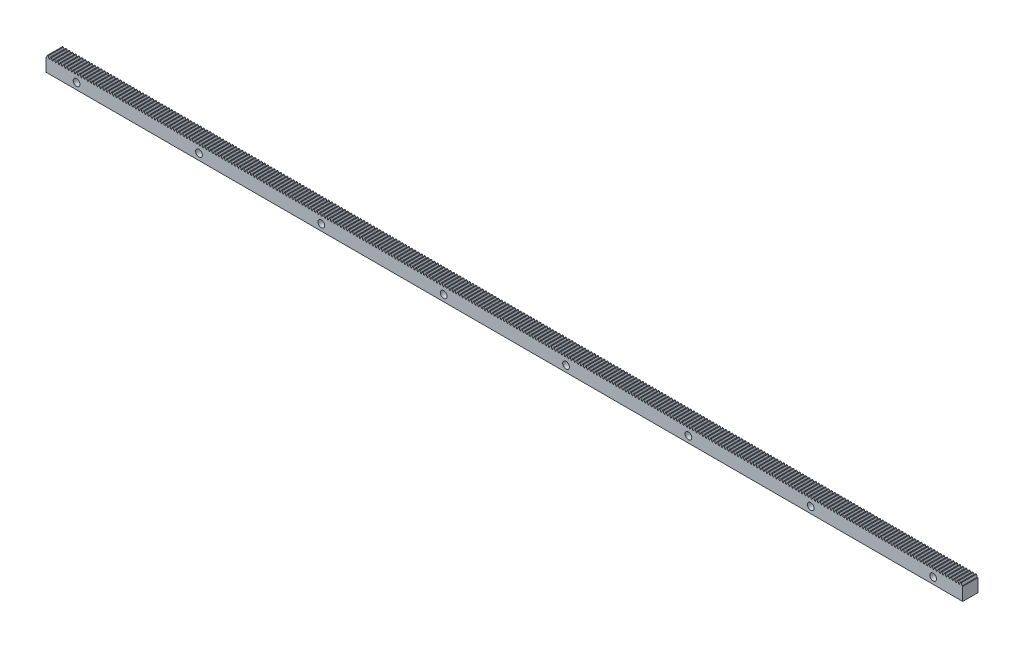
from build123d import *

# Parameters (mm, degrees)
BOSS_EXTRU_1_DEPTH                                  = 15
CBORE_FOR_M6_HEX_SOCKET_HEAD_CAP_SCREW1_D           = 6.6
CBORE_FOR_M6_HEX_SOCKET_HEAD_CAP_SCREW1_DEPTH       = 23
CBORE_FOR_M6_HEX_SOCKET_HEAD_CAP_SCREW1_CBORE_D     = 11
CBORE_FOR_M6_HEX_SOCKET_HEAD_CAP_SCREW1_CBORE_DEPTH = 6.4
CBORE_FOR_M6_HEX_SOCKET_HEAD_CAP_SCREW1_TIP         = 1.982840043


with BuildPart() as part:
    # Esquisse1 → Boss.-Extru.1 (new body)
    with BuildSketch(Plane.XY):
        Polygon((3.135070948, 7.8), (3.135070948, 0), (3.135070948, -5), (-895.88403, -5), (-895.88403, 7.8), (-895.359669052, 7.8), (-894.558930993, 10.000009736), (-893.716076461, 10.000009736), (-892.915315239, 7.8), (-892.218079052, 7.8), (-891.417340993, 10.000009736), (-890.574486461, 10.000009736), (-889.773725239, 7.8), (-889.076489052, 7.8), (-888.275750993, 10.000009736), (-887.432896461, 10.000009736), (-886.632135239, 7.8), (-885.934899052, 7.8), (-885.134160993, 10.000009736), (-884.291306461, 10.000009736), (-883.490545239, 7.8), (-882.793309052, 7.8), (-881.992570993, 10.000009736), (-881.149716461, 10.000009736), (-880.348955239, 7.8), (-879.651719052, 7.8), (-878.850980993, 10.000009736), (-878.008126461, 10.000009736), (-877.207365239, 7.8), (-876.510129052, 7.8), (-875.709390993, 10.000009736), (-874.866536461, 10.000009736), (-874.065775239, 7.8), (-873.368539052, 7.8), (-872.567800993, 10.000009736), (-871.724946461, 10.000009736), (-870.924185239, 7.8), (-870.226949052, 7.8), (-869.426210993, 10.000009736), (-868.583356461, 10.000009736), (-867.782595239, 7.8), (-867.085359052, 7.8), (-866.284620993, 10.000009736), (-865.441766461, 10.000009736), (-864.641005239, 7.8), (-863.943769052, 7.8), (-863.143030993, 10.000009736), (-862.300176461, 10.000009736), (-861.499415239, 7.8), (-860.802179052, 7.8), (-860.001440993, 10.000009736), (-859.158586461, 10.000009736), (-858.357825239, 7.8), (-857.660589052, 7.8), (-856.859850993, 10.000009736), (-856.016996461, 10.000009736), (-855.216235239, 7.8), (-854.518999052, 7.8), (-853.718260993, 10.000009736), (-852.875406461, 10.000009736), (-852.074645239, 7.8), (-851.377409052, 7.8), (-850.576670993, 10.000009736), (-849.733816461, 10.000009736), (-848.933055239, 7.8), (-848.235819052, 7.8), (-847.435080993, 10.000009736), (-846.592226461, 10.000009736), (-845.791465239, 7.8), (-845.094229052, 7.8), (-844.293490993, 10.000009736), (-843.450636461, 10.000009736), (-842.649875239, 7.8), (-841.952639052, 7.8), (-841.151900993, 10.000009736), (-840.309046461, 10.000009736), (-839.508285239, 7.8), (-838.811049052, 7.8), (-838.010310993, 10.000009736), (-837.167456461, 10.000009736), (-836.366695239, 7.8), (-835.669459052, 7.8), (-834.868720993, 10.000009736), (-834.025866461, 10.000009736), (-833.225105239, 7.8), (-832.527869052, 7.8), (-831.727130993, 10.000009736), (-830.884276461, 10.000009736), (-830.083515239, 7.8), (-829.386279052, 7.8), (-828.585540993, 10.000009736), (-827.742686461, 10.000009736), (-826.941925239, 7.8), (-826.244689052, 7.8), (-825.443950993, 10.000009736), (-824.601096461, 10.000009736), (-823.800335239, 7.8), (-823.103099052, 7.8), (-822.302360993, 10.000009736), (-821.459506461, 10.000009736), (-820.658745239, 7.8), (-819.961509052, 7.8), (-819.160770993, 10.000009736), (-818.317916461, 10.000009736), (-817.517155239, 7.8), (-816.819919052, 7.8), (-816.019180993, 10.000009736), (-815.176326461, 10.000009736), (-814.375565239, 7.8), (-813.678329052, 7.8), (-812.877590993, 10.000009736), (-812.034736461, 10.000009736), (-811.233975239, 7.8), (-810.536739052, 7.8), (-809.736000993, 10.000009736), (-808.893146461, 10.000009736), (-808.092385239, 7.8), (-807.395149052, 7.8), (-806.594410993, 10.000009736), (-805.751556461, 10.000009736), (-804.950795239, 7.8), (-804.253559052, 7.8), (-803.452820993, 10.000009736), (-802.609966461, 10.000009736), (-801.809205239, 7.8), (-801.111969052, 7.8), (-800.311230993, 10.000009736), (-799.468376461, 10.000009736), (-798.667615239, 7.8), (-797.970379052, 7.8), (-797.169640993, 10.000009736), (-796.326786461, 10.000009736), (-795.526025239, 7.8), (-794.828789052, 7.8), (-794.028050993, 10.000009736), (-793.185196461, 10.000009736), (-792.384435239, 7.8), (-791.687199052, 7.8), (-790.886460993, 10.000009736), (-790.043606461, 10.000009736), (-789.242845239, 7.8), (-788.545609052, 7.8), (-787.744870993, 10.000009736), (-786.902016461, 10.000009736), (-786.101255239, 7.8), (-785.404019052, 7.8), (-784.603280993, 10.000009736), (-783.760426461, 10.000009736), (-782.959665239, 7.8), (-782.262429052, 7.8), (-781.461690993, 10.000009736), (-780.618836461, 10.000009736), (-779.818075239, 7.8), (-779.120839052, 7.8), (-778.320100993, 10.000009736), (-777.477246461, 10.000009736), (-776.676485239, 7.8), (-775.979249052, 7.8), (-775.178510993, 10.000009736), (-774.335656461, 10.000009736), (-773.534895239, 7.8), (-772.837659052, 7.8), (-772.036920993, 10.000009736), (-771.194066461, 10.000009736), (-770.393305239, 7.8), (-769.696069052, 7.8), (-768.895330993, 10.000009736), (-768.052476461, 10.000009736), (-767.251715239, 7.8), (-766.554479052, 7.8), (-765.753740993, 10.000009736), (-764.910886461, 10.000009736), (-764.110125239, 7.8), (-763.412889052, 7.8), (-762.612150993, 10.000009736), (-761.769296461, 10.000009736), (-760.968535239, 7.8), (-760.271299052, 7.8), (-759.470560993, 10.000009736), (-758.627706461, 10.000009736), (-757.826945239, 7.8), (-757.129709052, 7.8), (-756.328970993, 10.000009736), (-755.486116461, 10.000009736), (-754.685355239, 7.8), (-753.988119052, 7.8), (-753.187380993, 10.000009736), (-752.344526461, 10.000009736), (-751.543765239, 7.8), (-750.846529052, 7.8), (-750.045790993, 10.000009736), (-749.202936461, 10.000009736), (-748.402175239, 7.8), (-747.704939052, 7.8), (-746.904200993, 10.000009736), (-746.061346461, 10.000009736), (-745.260585239, 7.8), (-744.563349052, 7.8), (-743.762610993, 10.000009736), (-742.919756461, 10.000009736), (-742.118995239, 7.8), (-741.421759052, 7.8), (-740.621020993, 10.000009736), (-739.778166461, 10.000009736), (-738.977405239, 7.8), (-738.280169052, 7.8), (-737.479430993, 10.000009736), (-736.636576461, 10.000009736), (-735.835815239, 7.8), (-735.138579052, 7.8), (-734.337840993, 10.000009736), (-733.494986461, 10.000009736), (-732.694225239, 7.8), (-731.996989052, 7.8), (-731.196250993, 10.000009736), (-730.353396461, 10.000009736), (-729.552635239, 7.8), (-728.855399052, 7.8), (-728.054660993, 10.000009736), (-727.211806461, 10.000009736), (-726.411045239, 7.8), (-725.713809052, 7.8), (-724.913070993, 10.000009736), (-724.070216461, 10.000009736), (-723.269455239, 7.8), (-722.572219052, 7.8), (-721.771480993, 10.000009736), (-720.928626461, 10.000009736), (-720.127865239, 7.8), (-719.430629052, 7.8), (-718.629890993, 10.000009736), (-717.787036461, 10.000009736), (-716.986275239, 7.8), (-716.289039052, 7.8), (-715.488300993, 10.000009736), (-714.645446461, 10.000009736), (-713.844685239, 7.8), (-713.147449052, 7.8), (-712.346710993, 10.000009736), (-711.503856461, 10.000009736), (-710.703095239, 7.8), (-710.005859052, 7.8), (-709.205120993, 10.000009736), (-708.362266461, 10.000009736), (-707.561505239, 7.8), (-706.864269052, 7.8), (-706.063530993, 10.000009736), (-705.220676461, 10.000009736), (-704.419915239, 7.8), (-703.722679052, 7.8), (-702.921940993, 10.000009736), (-702.079086461, 10.000009736), (-701.278325239, 7.8), (-700.581089052, 7.8), (-699.780350993, 10.000009736), (-698.937496461, 10.000009736), (-698.136735239, 7.8), (-697.439499052, 7.8), (-696.638760993, 10.000009736), (-695.795906461, 10.000009736), (-694.995145239, 7.8), (-694.297909052, 7.8), (-693.497170993, 10.000009736), (-692.654316461, 10.000009736), (-691.853555239, 7.8), (-691.156319052, 7.8), (-690.355580993, 10.000009736), (-689.512726461, 10.000009736), (-688.711965239, 7.8), (-688.014729052, 7.8), (-687.213990993, 10.000009736), (-686.371136461, 10.000009736), (-685.570375239, 7.8), (-684.873139052, 7.8), (-684.072400993, 10.000009736), (-683.229546461, 10.000009736), (-682.428785239, 7.8), (-681.731549052, 7.8), (-680.930810993, 10.000009736), (-680.087956461, 10.000009736), (-679.287195239, 7.8), (-678.589959052, 7.8), (-677.789220993, 10.000009736), (-676.946366461, 10.000009736), (-676.145605239, 7.8), (-675.448369052, 7.8), (-674.647630993, 10.000009736), (-673.804776462, 10.000009736), (-673.004015239, 7.8), (-672.306779052, 7.8), (-671.506040993, 10.000009736), (-670.663186462, 10.000009736), (-669.862425239, 7.8), (-669.165189052, 7.8), (-668.364450993, 10.000009736), (-667.521596462, 10.000009736), (-666.720835239, 7.8), (-666.023599052, 7.8), (-665.222860993, 10.000009736), (-664.380006462, 10.000009736), (-663.579245239, 7.8), (-662.882009052, 7.8), (-662.081270993, 10.000009736), (-661.238416462, 10.000009736), (-660.437655239, 7.8), (-659.740419052, 7.8), (-658.939680993, 10.000009736), (-658.096826462, 10.000009736), (-657.296065239, 7.8), (-656.598829052, 7.8), (-655.798090993, 10.000009736), (-654.955236462, 10.000009736), (-654.154475239, 7.8), (-653.457239052, 7.8), (-652.656500993, 10.000009736), (-651.813646462, 10.000009736), (-651.012885239, 7.8), (-650.315649052, 7.8), (-649.514910993, 10.000009736), (-648.672056462, 10.000009736), (-647.871295239, 7.8), (-647.174059052, 7.8), (-646.373320993, 10.000009736), (-645.530466462, 10.000009736), (-644.729705239, 7.8), (-644.032469052, 7.8), (-643.231730993, 10.000009736), (-642.388876462, 10.000009736), (-641.588115239, 7.8), (-640.890879052, 7.8), (-640.090140993, 10.000009736), (-639.247286462, 10.000009736), (-638.446525239, 7.8), (-637.749289052, 7.8), (-636.948550993, 10.000009736), (-636.105696462, 10.000009736), (-635.304935239, 7.8), (-634.607699052, 7.8), (-633.806960993, 10.000009736), (-632.964106462, 10.000009736), (-632.163345239, 7.8), (-631.466109052, 7.8), (-630.665370993, 10.000009736), (-629.822516462, 10.000009736), (-629.021755239, 7.8), (-628.324519052, 7.8), (-627.523780993, 10.000009736), (-626.680926462, 10.000009736), (-625.880165239, 7.8), (-625.182929052, 7.8), (-624.382190993, 10.000009736), (-623.539336462, 10.000009736), (-622.738575239, 7.8), (-622.041339052, 7.8), (-621.240600993, 10.000009736), (-620.397746462, 10.000009736), (-619.596985239, 7.8), (-618.899749052, 7.8), (-618.099010993, 10.000009736), (-617.256156462, 10.000009736), (-616.455395239, 7.8), (-615.758159052, 7.8), (-614.957420993, 10.000009736), (-614.114566462, 10.000009736), (-613.313805239, 7.8), (-612.616569052, 7.8), (-611.815830993, 10.000009736), (-610.972976462, 10.000009736), (-610.172215239, 7.8), (-609.474979052, 7.8), (-608.674240993, 10.000009736), (-607.831386462, 10.000009736), (-607.030625239, 7.8), (-606.333389052, 7.8), (-605.532650993, 10.000009736), (-604.689796462, 10.000009736), (-603.889035239, 7.8), (-603.191799052, 7.8), (-602.391060993, 10.000009736), (-601.548206462, 10.000009736), (-600.747445239, 7.8), (-600.050209052, 7.8), (-599.249470993, 10.000009736), (-598.406616462, 10.000009736), (-597.605855239, 7.8), (-596.908619052, 7.8), (-596.107880993, 10.000009736), (-595.265026462, 10.000009736), (-594.464265239, 7.8), (-593.767029052, 7.8), (-592.966290993, 10.000009736), (-592.123436462, 10.000009736), (-591.322675239, 7.8), (-590.625439052, 7.8), (-589.824700993, 10.000009736), (-588.981846462, 10.000009736), (-588.181085239, 7.8), (-587.483849052, 7.8), (-586.683110993, 10.000009736), (-585.840256462, 10.000009736), (-585.039495239, 7.8), (-584.342259052, 7.8), (-583.541520993, 10.000009736), (-582.698666462, 10.000009736), (-581.897905239, 7.8), (-581.200669052, 7.8), (-580.399930993, 10.000009736), (-579.557076462, 10.000009736), (-578.756315239, 7.8), (-578.059079052, 7.8), (-577.258340993, 10.000009736), (-576.415486462, 10.000009736), (-575.614725239, 7.8), (-574.917489052, 7.8), (-574.116750993, 10.000009736), (-573.273896462, 10.000009736), (-572.473135239, 7.8), (-571.775899052, 7.8), (-570.975160993, 10.000009736), (-570.132306462, 10.000009736), (-569.331545239, 7.8), (-568.634309052, 7.8), (-567.833570993, 10.000009736), (-566.990716462, 10.000009736), (-566.189955239, 7.8), (-565.492719052, 7.8), (-564.691980993, 10.000009736), (-563.849126462, 10.000009736), (-563.048365239, 7.8), (-562.351129052, 7.8), (-561.550390993, 10.000009736), (-560.707536462, 10.000009736), (-559.906775239, 7.8), (-559.209539052, 7.8), (-558.408800993, 10.000009736), (-557.565946462, 10.000009736), (-556.765185239, 7.8), (-556.067949052, 7.8), (-555.267210993, 10.000009736), (-554.424356462, 10.000009736), (-553.623595239, 7.8), (-552.926359052, 7.8), (-552.125620993, 10.000009736), (-551.282766462, 10.000009736), (-550.482005239, 7.8), (-549.784769052, 7.8), (-548.984030993, 10.000009736), (-548.141176462, 10.000009736), (-547.340415239, 7.8), (-546.643179052, 7.8), (-545.842440993, 10.000009736), (-544.999586462, 10.000009736), (-544.198825239, 7.8), (-543.501589052, 7.8), (-542.700850993, 10.000009736), (-541.857996462, 10.000009736), (-541.057235239, 7.8), (-540.359999052, 7.8), (-539.559260993, 10.000009736), (-538.716406462, 10.000009736), (-537.915645239, 7.8), (-537.218409052, 7.8), (-536.417670993, 10.000009736), (-535.574816462, 10.000009736), (-534.774055239, 7.8), (-534.076819052, 7.8), (-533.276080993, 10.000009736), (-532.433226462, 10.000009736), (-531.632465239, 7.8), (-530.935229052, 7.8), (-530.134490993, 10.000009736), (-529.291636462, 10.000009736), (-528.490875239, 7.8), (-527.793639052, 7.8), (-526.992900993, 10.000009736), (-526.150046462, 10.000009736), (-525.349285239, 7.8), (-524.652049052, 7.8), (-523.851310993, 10.000009736), (-523.008456462, 10.000009736), (-522.207695239, 7.8), (-521.510459052, 7.8), (-520.709720993, 10.000009736), (-519.866866462, 10.000009736), (-519.066105239, 7.8), (-518.368869052, 7.8), (-517.568130993, 10.000009736), (-516.725276462, 10.000009736), (-515.924515239, 7.8), (-515.227279052, 7.8), (-514.426540993, 10.000009736), (-513.583686462, 10.000009736), (-512.782925239, 7.8), (-512.085689052, 7.8), (-511.284950993, 10.000009736), (-510.442096462, 10.000009736), (-509.641335239, 7.8), (-508.944099052, 7.8), (-508.143360993, 10.000009736), (-507.300506462, 10.000009736), (-506.499745239, 7.8), (-505.802509052, 7.8), (-505.001770993, 10.000009736), (-504.158916462, 10.000009736), (-503.358155239, 7.8), (-502.660919052, 7.8), (-501.860180993, 10.000009736), (-501.017326462, 10.000009736), (-500.216565239, 7.8), (-499.519329052, 7.8), (-498.718590993, 10.000009736), (-497.875736462, 10.000009736), (-497.074975239, 7.8), (-496.377739052, 7.8), (-495.577000993, 10.000009736), (-494.734146462, 10.000009736), (-493.933385239, 7.8), (-493.236149052, 7.8), (-492.435410993, 10.000009736), (-491.592556462, 10.000009736), (-490.791795239, 7.8), (-490.094559052, 7.8), (-489.293820993, 10.000009736), (-488.450966462, 10.000009736), (-487.650205239, 7.8), (-486.952969052, 7.8), (-486.152230993, 10.000009736), (-485.309376462, 10.000009736), (-484.508615239, 7.8), (-483.811379052, 7.8), (-483.010640993, 10.000009736), (-482.167786462, 10.000009736), (-481.367025239, 7.8), (-480.669789052, 7.8), (-479.869050993, 10.000009736), (-479.026196462, 10.000009736), (-478.225435239, 7.8), (-477.528199052, 7.8), (-476.727460993, 10.000009736), (-475.884606462, 10.000009736), (-475.083845239, 7.8), (-474.386609052, 7.8), (-473.585870993, 10.000009736), (-472.743016462, 10.000009736), (-471.942255239, 7.8), (-471.245019052, 7.8), (-470.444280993, 10.000009736), (-469.601426462, 10.000009736), (-468.800665239, 7.8), (-468.103429052, 7.8), (-467.302690993, 10.000009736), (-466.459836462, 10.000009736), (-465.659075239, 7.8), (-464.961839052, 7.8), (-464.161100993, 10.000009736), (-463.318246462, 10.000009736), (-462.517485239, 7.8), (-461.820249052, 7.8), (-461.019510993, 10.000009736), (-460.176656462, 10.000009736), (-459.375895239, 7.8), (-458.678659052, 7.8), (-457.877920993, 10.000009736), (-457.035066462, 10.000009736), (-456.234305239, 7.8), (-455.537069052, 7.8), (-454.736330993, 10.000009736), (-453.893476462, 10.000009736), (-453.092715239, 7.8), (-452.395479052, 7.8), (-451.594740993, 10.000009736), (-450.751886462, 10.000009736), (-449.951125239, 7.8), (-449.253889052, 7.8), (-448.453150993, 10.000009736), (-447.610296462, 10.000009736), (-446.809535239, 7.8), (-446.112299052, 7.8), (-445.311560993, 10.000009736), (-444.468706462, 10.000009736), (-443.667945239, 7.8), (-442.970709052, 7.8), (-442.169970993, 10.000009736), (-441.327116462, 10.000009736), (-440.526355239, 7.8), (-439.829119052, 7.8), (-439.028380993, 10.000009736), (-438.185526462, 10.000009736), (-437.384765239, 7.8), (-436.687529052, 7.8), (-435.886790993, 10.000009736), (-435.043936462, 10.000009736), (-434.243175239, 7.8), (-433.545939052, 7.8), (-432.745200993, 10.000009736), (-431.902346462, 10.000009736), (-431.101585239, 7.8), (-430.404349052, 7.8), (-429.603610993, 10.000009736), (-428.760756462, 10.000009736), (-427.959995239, 7.8), (-427.262759052, 7.8), (-426.462020993, 10.000009736), (-425.619166462, 10.000009736), (-424.818405239, 7.8), (-424.121169052, 7.8), (-423.320430993, 10.000009736), (-422.477576462, 10.000009736), (-421.676815239, 7.8), (-420.979579052, 7.8), (-420.178840993, 10.000009736), (-419.335986462, 10.000009736), (-418.535225239, 7.8), (-417.837989052, 7.8), (-417.037250993, 10.000009736), (-416.194396462, 10.000009736), (-415.393635239, 7.8), (-414.696399052, 7.8), (-413.895660993, 10.000009736), (-413.052806462, 10.000009736), (-412.252045239, 7.8), (-411.554809052, 7.8), (-410.754070993, 10.000009736), (-409.911216462, 10.000009736), (-409.110455239, 7.8), (-408.413219052, 7.8), (-407.612480993, 10.000009736), (-406.769626462, 10.000009736), (-405.968865239, 7.8), (-405.271629052, 7.8), (-404.470890993, 10.000009736), (-403.628036462, 10.000009736), (-402.827275239, 7.8), (-402.130039052, 7.8), (-401.329300993, 10.000009736), (-400.486446462, 10.000009736), (-399.685685239, 7.8), (-398.988449052, 7.8), (-398.187710993, 10.000009736), (-397.344856462, 10.000009736), (-396.544095239, 7.8), (-395.846859052, 7.8), (-395.046120993, 10.000009736), (-394.203266462, 10.000009736), (-393.402505239, 7.8), (-392.705269052, 7.8), (-391.904530993, 10.000009736), (-391.061676462, 10.000009736), (-390.260915239, 7.8), (-389.563679052, 7.8), (-388.762940993, 10.000009736), (-387.920086462, 10.000009736), (-387.119325239, 7.8), (-386.422089052, 7.8), (-385.621350993, 10.000009736), (-384.778496462, 10.000009736), (-383.977735239, 7.8), (-383.280499052, 7.8), (-382.479760993, 10.000009736), (-381.636906462, 10.000009736), (-380.836145239, 7.8), (-380.138909052, 7.8), (-379.338170993, 10.000009736), (-378.495316462, 10.000009736), (-377.694555239, 7.8), (-376.997319052, 7.8), (-376.196580993, 10.000009736), (-375.353726462, 10.000009736), (-374.552965239, 7.8), (-373.855729052, 7.8), (-373.054990993, 10.000009736), (-372.212136462, 10.000009736), (-371.411375239, 7.8), (-370.714139052, 7.8), (-369.913400993, 10.000009736), (-369.070546462, 10.000009736), (-368.269785239, 7.8), (-367.572549052, 7.8), (-366.771810993, 10.000009736), (-365.928956462, 10.000009736), (-365.128195239, 7.8), (-364.430959052, 7.8), (-363.630220993, 10.000009736), (-362.787366462, 10.000009736), (-361.986605239, 7.8), (-361.289369052, 7.8), (-360.488630993, 10.000009736), (-359.645776462, 10.000009736), (-358.845015239, 7.8), (-358.147779052, 7.8), (-357.347040993, 10.000009736), (-356.504186462, 10.000009736), (-355.703425239, 7.8), (-355.006189052, 7.8), (-354.205450993, 10.000009736), (-353.362596462, 10.000009736), (-352.561835239, 7.8), (-351.864599052, 7.8), (-351.063860993, 10.000009736), (-350.221006462, 10.000009736), (-349.420245239, 7.8), (-348.723009052, 7.8), (-347.922270993, 10.000009736), (-347.079416462, 10.000009736), (-346.278655239, 7.8), (-345.581419052, 7.8), (-344.780680993, 10.000009736), (-343.937826462, 10.000009736), (-343.137065239, 7.8), (-342.439829052, 7.8), (-341.639090993, 10.000009736), (-340.796236462, 10.000009736), (-339.995475239, 7.8), (-339.298239052, 7.8), (-338.497500993, 10.000009736), (-337.654646462, 10.000009736), (-336.853885239, 7.8), (-336.156649052, 7.8), (-335.355910993, 10.000009736), (-334.513056462, 10.000009736), (-333.712295239, 7.8), (-333.015059052, 7.8), (-332.214320993, 10.000009736), (-331.371466462, 10.000009736), (-330.570705239, 7.8), (-329.873469052, 7.8), (-329.072730993, 10.000009736), (-328.229876462, 10.000009736), (-327.429115239, 7.8), (-326.731879052, 7.8), (-325.931140993, 10.000009736), (-325.088286462, 10.000009736), (-324.287525239, 7.8), (-323.590289052, 7.8), (-322.789550993, 10.000009736), (-321.946696462, 10.000009736), (-321.145935239, 7.8), (-320.448699052, 7.8), (-319.647960993, 10.000009736), (-318.805106462, 10.000009736), (-318.004345239, 7.8), (-317.307109052, 7.8), (-316.506370993, 10.000009736), (-315.663516462, 10.000009736), (-314.862755239, 7.8), (-314.165519052, 7.8), (-313.364780993, 10.000009736), (-312.521926462, 10.000009736), (-311.721165239, 7.8), (-311.023929052, 7.8), (-310.223190993, 10.000009736), (-309.380336462, 10.000009736), (-308.579575239, 7.8), (-307.882339052, 7.8), (-307.081600993, 10.000009736), (-306.238746462, 10.000009736), (-305.437985239, 7.8), (-304.740749052, 7.8), (-303.940010993, 10.000009736), (-303.097156462, 10.000009736), (-302.296395239, 7.8), (-301.599159052, 7.8), (-300.798420993, 10.000009736), (-299.955566462, 10.000009736), (-299.154805239, 7.8), (-298.457569052, 7.8), (-297.656830993, 10.000009736), (-296.813976462, 10.000009736), (-296.013215239, 7.8), (-295.315979052, 7.8), (-294.515240993, 10.000009736), (-293.672386462, 10.000009736), (-292.871625239, 7.8), (-292.174389052, 7.8), (-291.373650993, 10.000009736), (-290.530796462, 10.000009736), (-289.730035239, 7.8), (-289.032799052, 7.8), (-288.232060993, 10.000009736), (-287.389206462, 10.000009736), (-286.588445239, 7.8), (-285.891209052, 7.8), (-285.090470993, 10.000009736), (-284.247616462, 10.000009736), (-283.446855239, 7.8), (-282.749619052, 7.8), (-281.948880993, 10.000009736), (-281.106026462, 10.000009736), (-280.305265239, 7.8), (-279.608029052, 7.8), (-278.807290993, 10.000009736), (-277.964436462, 10.000009736), (-277.163675239, 7.8), (-276.466439052, 7.8), (-275.665700993, 10.000009736), (-274.822846462, 10.000009736), (-274.022085239, 7.8), (-273.324849052, 7.8), (-272.524110993, 10.000009736), (-271.681256462, 10.000009736), (-270.880495239, 7.8), (-270.183259052, 7.8), (-269.382520993, 10.000009736), (-268.539666462, 10.000009736), (-267.738905239, 7.8), (-267.041669052, 7.8), (-266.240930993, 10.000009736), (-265.398076462, 10.000009736), (-264.597315239, 7.8), (-263.900079052, 7.8), (-263.099340993, 10.000009736), (-262.256486462, 10.000009736), (-261.455725239, 7.8), (-260.758489052, 7.8), (-259.957750993, 10.000009736), (-259.114896462, 10.000009736), (-258.314135239, 7.8), (-257.616899052, 7.8), (-256.816160993, 10.000009736), (-255.973306462, 10.000009736), (-255.172545239, 7.8), (-254.475309052, 7.8), (-253.674570993, 10.000009736), (-252.831716462, 10.000009736), (-252.030955239, 7.8), (-251.333719052, 7.8), (-250.532980993, 10.000009736), (-249.690126462, 10.000009736), (-248.889365239, 7.8), (-248.192129052, 7.8), (-247.391390993, 10.000009736), (-246.548536462, 10.000009736), (-245.747775239, 7.8), (-245.050539052, 7.8), (-244.249800993, 10.000009736), (-243.406946462, 10.000009736), (-242.606185239, 7.8), (-241.908949052, 7.8), (-241.108210993, 10.000009736), (-240.265356462, 10.000009736), (-239.464595239, 7.8), (-238.767359052, 7.8), (-237.966620993, 10.000009736), (-237.123766462, 10.000009736), (-236.323005239, 7.8), (-235.625769052, 7.8), (-234.825030993, 10.000009736), (-233.982176462, 10.000009736), (-233.181415239, 7.8), (-232.484179052, 7.8), (-231.683440993, 10.000009736), (-230.840586462, 10.000009736), (-230.039825239, 7.8), (-229.342589052, 7.8), (-228.541850993, 10.000009736), (-227.698996462, 10.000009736), (-226.898235239, 7.8), (-226.200999052, 7.8), (-225.400260993, 10.000009736), (-224.557406462, 10.000009736), (-223.756645239, 7.8), (-223.059409052, 7.8), (-222.258670993, 10.000009736), (-221.415816462, 10.000009736), (-220.615055239, 7.8), (-219.917819052, 7.8), (-219.117080993, 10.000009736), (-218.274226462, 10.000009736), (-217.473465239, 7.8), (-216.776229052, 7.8), (-215.975490993, 10.000009736), (-215.132636462, 10.000009736), (-214.331875239, 7.8), (-213.634639052, 7.8), (-212.833900993, 10.000009736), (-211.991046462, 10.000009736), (-211.190285239, 7.8), (-210.493049052, 7.8), (-209.692310993, 10.000009736), (-208.849456462, 10.000009736), (-208.048695239, 7.8), (-207.351459052, 7.8), (-206.550720993, 10.000009736), (-205.707866462, 10.000009736), (-204.907105239, 7.8), (-204.209869052, 7.8), (-203.409130993, 10.000009736), (-202.566276462, 10.000009736), (-201.765515239, 7.8), (-201.068279052, 7.8), (-200.267540993, 10.000009736), (-199.424686462, 10.000009736), (-198.623925239, 7.8), (-197.926689052, 7.8), (-197.125950993, 10.000009736), (-196.283096462, 10.000009736), (-195.482335239, 7.8), (-194.785099052, 7.8), (-193.984360993, 10.000009736), (-193.141506462, 10.000009736), (-192.340745239, 7.8), (-191.643509052, 7.8), (-190.842770993, 10.000009736), (-189.999916462, 10.000009736), (-189.199155239, 7.8), (-188.501919052, 7.8), (-187.701180993, 10.000009736), (-186.858326462, 10.000009736), (-186.057565239, 7.8), (-185.360329052, 7.8), (-184.559590993, 10.000009736), (-183.716736462, 10.000009736), (-182.915975239, 7.8), (-182.218739052, 7.8), (-181.418000993, 10.000009736), (-180.575146462, 10.000009736), (-179.774385239, 7.8), (-179.077149052, 7.8), (-178.276410993, 10.000009736), (-177.433556462, 10.000009736), (-176.632795239, 7.8), (-175.935559052, 7.8), (-175.134820993, 10.000009736), (-174.291966462, 10.000009736), (-173.491205239, 7.8), (-172.793969052, 7.8), (-171.993230993, 10.000009736), (-171.150376462, 10.000009736), (-170.349615239, 7.8), (-169.652379052, 7.8), (-168.851640993, 10.000009736), (-168.008786462, 10.000009736), (-167.208025239, 7.8), (-166.510789052, 7.8), (-165.710050993, 10.000009736), (-164.867196462, 10.000009736), (-164.066435239, 7.8), (-163.369199052, 7.8), (-162.568460993, 10.000009736), (-161.725606462, 10.000009736), (-160.924845239, 7.8), (-160.227609052, 7.8), (-159.426870993, 10.000009736), (-158.584016462, 10.000009736), (-157.783255239, 7.8), (-157.086019052, 7.8), (-156.285280993, 10.000009736), (-155.442426462, 10.000009736), (-154.641665239, 7.8), (-153.944429052, 7.8), (-153.143690993, 10.000009736), (-152.300836462, 10.000009736), (-151.500075239, 7.8), (-150.802839052, 7.8), (-150.002100993, 10.000009736), (-149.159246462, 10.000009736), (-148.358485239, 7.8), (-147.661249052, 7.8), (-146.860510993, 10.000009736), (-146.017656462, 10.000009736), (-145.216895239, 7.8), (-144.519659052, 7.8), (-143.718920993, 10.000009736), (-142.876066462, 10.000009736), (-142.075305239, 7.8), (-141.378069052, 7.8), (-140.577330993, 10.000009736), (-139.734476462, 10.000009736), (-138.933715239, 7.8), (-138.236479052, 7.8), (-137.435740993, 10.000009736), (-136.592886462, 10.000009736), (-135.792125239, 7.8), (-135.094889052, 7.8), (-134.294150993, 10.000009736), (-133.451296462, 10.000009736), (-132.650535239, 7.8), (-131.953299052, 7.8), (-131.152560993, 10.000009736), (-130.309706462, 10.000009736), (-129.508945239, 7.8), (-128.811709052, 7.8), (-128.010970993, 10.000009736), (-127.168116462, 10.000009736), (-126.367355239, 7.8), (-125.670119052, 7.8), (-124.869380993, 10.000009736), (-124.026526462, 10.000009736), (-123.225765239, 7.8), (-122.528529052, 7.8), (-121.727790993, 10.000009736), (-120.884936462, 10.000009736), (-120.084175239, 7.8), (-119.386939052, 7.8), (-118.586200993, 10.000009736), (-117.743346462, 10.000009736), (-116.942585239, 7.8), (-116.245349052, 7.8), (-115.444610993, 10.000009736), (-114.601756462, 10.000009736), (-113.800995239, 7.8), (-113.103759052, 7.8), (-112.303020993, 10.000009736), (-111.460166462, 10.000009736), (-110.659405239, 7.8), (-109.962169052, 7.8), (-109.161430993, 10.000009736), (-108.318576462, 10.000009736), (-107.517815239, 7.8), (-106.820579052, 7.8), (-106.019840993, 10.000009736), (-105.176986462, 10.000009736), (-104.376225239, 7.8), (-103.678989052, 7.8), (-102.878250993, 10.000009736), (-102.035396462, 10.000009736), (-101.234635239, 7.8), (-100.537399052, 7.8), (-99.736660993, 10.000009736), (-98.893806462, 10.000009736), (-98.093045239, 7.8), (-97.395809052, 7.8), (-96.595070993, 10.000009736), (-95.752216462, 10.000009736), (-94.951455239, 7.8), (-94.254219052, 7.8), (-93.453480993, 10.000009736), (-92.610626462, 10.000009736), (-91.809865239, 7.8), (-91.112629052, 7.8), (-90.311890993, 10.000009736), (-89.469036462, 10.000009736), (-88.668275239, 7.8), (-87.971039052, 7.8), (-87.170300993, 10.000009736), (-86.327446462, 10.000009736), (-85.526685239, 7.8), (-84.829449052, 7.8), (-84.028710993, 10.000009736), (-83.185856462, 10.000009736), (-82.385095239, 7.8), (-81.687859052, 7.8), (-80.887120993, 10.000009736), (-80.044266462, 10.000009736), (-79.243505239, 7.8), (-78.546269052, 7.8), (-77.745530993, 10.000009736), (-76.902676462, 10.000009736), (-76.101915239, 7.8), (-75.404679052, 7.8), (-74.603940993, 10.000009736), (-73.761086462, 10.000009736), (-72.960325239, 7.8), (-72.263089052, 7.8), (-71.462350993, 10.000009736), (-70.619496462, 10.000009736), (-69.818735239, 7.8), (-69.121499052, 7.8), (-68.320760993, 10.000009736), (-67.477906462, 10.000009736), (-66.677145239, 7.8), (-65.979909052, 7.8), (-65.179170993, 10.000009736), (-64.336316462, 10.000009736), (-63.535555239, 7.8), (-62.838319052, 7.8), (-62.037580993, 10.000009736), (-61.194726462, 10.000009736), (-60.393965239, 7.8), (-59.696729052, 7.8), (-58.895990993, 10.000009736), (-58.053136462, 10.000009736), (-57.252375239, 7.8), (-56.555139052, 7.8), (-55.754400993, 10.000009736), (-54.911546462, 10.000009736), (-54.110785239, 7.8), (-53.413549052, 7.8), (-52.612810993, 10.000009736), (-51.769956462, 10.000009736), (-50.969195239, 7.8), (-50.271959052, 7.8), (-49.471220993, 10.000009736), (-48.628366462, 10.000009736), (-47.827605239, 7.8), (-47.130369052, 7.8), (-46.329630993, 10.000009736), (-45.486776462, 10.000009736), (-44.686015239, 7.8), (-43.988779052, 7.8), (-43.188040993, 10.000009736), (-42.345186462, 10.000009736), (-41.544425239, 7.8), (-40.847189052, 7.8), (-40.046450993, 10.000009736), (-39.203596462, 10.000009736), (-38.402835239, 7.8), (-37.705599052, 7.8), (-36.904860993, 10.000009736), (-36.062006462, 10.000009736), (-35.261245239, 7.8), (-34.564009052, 7.8), (-33.763270993, 10.000009736), (-32.920416462, 10.000009736), (-32.119655239, 7.8), (-31.422419052, 7.8), (-30.621680993, 10.000009736), (-29.778826462, 10.000009736), (-28.978065239, 7.8), (-28.280829052, 7.8), (-27.480090993, 10.000009736), (-26.637236462, 10.000009736), (-25.836475239, 7.8), (-25.139239052, 7.8), (-24.338500993, 10.000009736), (-23.495646462, 10.000009736), (-22.694885239, 7.8), (-21.997649052, 7.8), (-21.196910993, 10.000009736), (-20.354056462, 10.000009736), (-19.553295239, 7.8), (-18.856059052, 7.8), (-18.055320993, 10.000009736), (-17.212466462, 10.000009736), (-16.411705239, 7.8), (-15.714469052, 7.8), (-14.913730993, 10.000009736), (-14.070876462, 10.000009736), (-13.270115239, 7.8), (-12.572879052, 7.8), (-11.772140993, 10.000009736), (-10.929286462, 10.000009736), (-10.128525239, 7.8), (-9.431289052, 7.8), (-8.630550993, 10.000009736), (-7.787696462, 10.000009736), (-6.986935239, 7.8), (-6.289699052, 7.8), (-5.488960993, 10.000009736), (-4.646106462, 10.000009736), (-3.845345239, 7.8), (-3.148109052, 7.8), (-2.347370993, 10.000009736), (-1.504516462, 10.000009736), (-0.703755239, 7.8), (-0.006519052, 7.8), (0.794219007, 10.000009736), (1.637073538, 10.000009736), (2.437834761, 7.8), align=None)
    extrude(amount=BOSS_EXTRU_1_DEPTH)

    # CBORE for M6 Hex Socket Head Cap Screw1
    with Locations(Plane(origin=(0, 0, 0), x_dir=(-1, 0, 0), z_dir=(0, 0, -1))):
        with Locations((865.88403, 1.25), (745.88403, 1.25), (625.88403, 1.25), (505.88403, 1.25), (385.88403, 1.25), (265.88403, 1.25), (145.88403, 1.25), (25.88403, 1.25)):
            CounterBoreHole(CBORE_FOR_M6_HEX_SOCKET_HEAD_CAP_SCREW1_D / 2, CBORE_FOR_M6_HEX_SOCKET_HEAD_CAP_SCREW1_CBORE_D / 2, CBORE_FOR_M6_HEX_SOCKET_HEAD_CAP_SCREW1_CBORE_DEPTH, depth=CBORE_FOR_M6_HEX_SOCKET_HEAD_CAP_SCREW1_DEPTH)
            with Locations((0, 0, -(CBORE_FOR_M6_HEX_SOCKET_HEAD_CAP_SCREW1_DEPTH + CBORE_FOR_M6_HEX_SOCKET_HEAD_CAP_SCREW1_TIP / 2))):  # 118° drill point
                Cone(0, CBORE_FOR_M6_HEX_SOCKET_HEAD_CAP_SCREW1_D / 2, CBORE_FOR_M6_HEX_SOCKET_HEAD_CAP_SCREW1_TIP, mode=Mode.SUBTRACT)


solid = part.part
